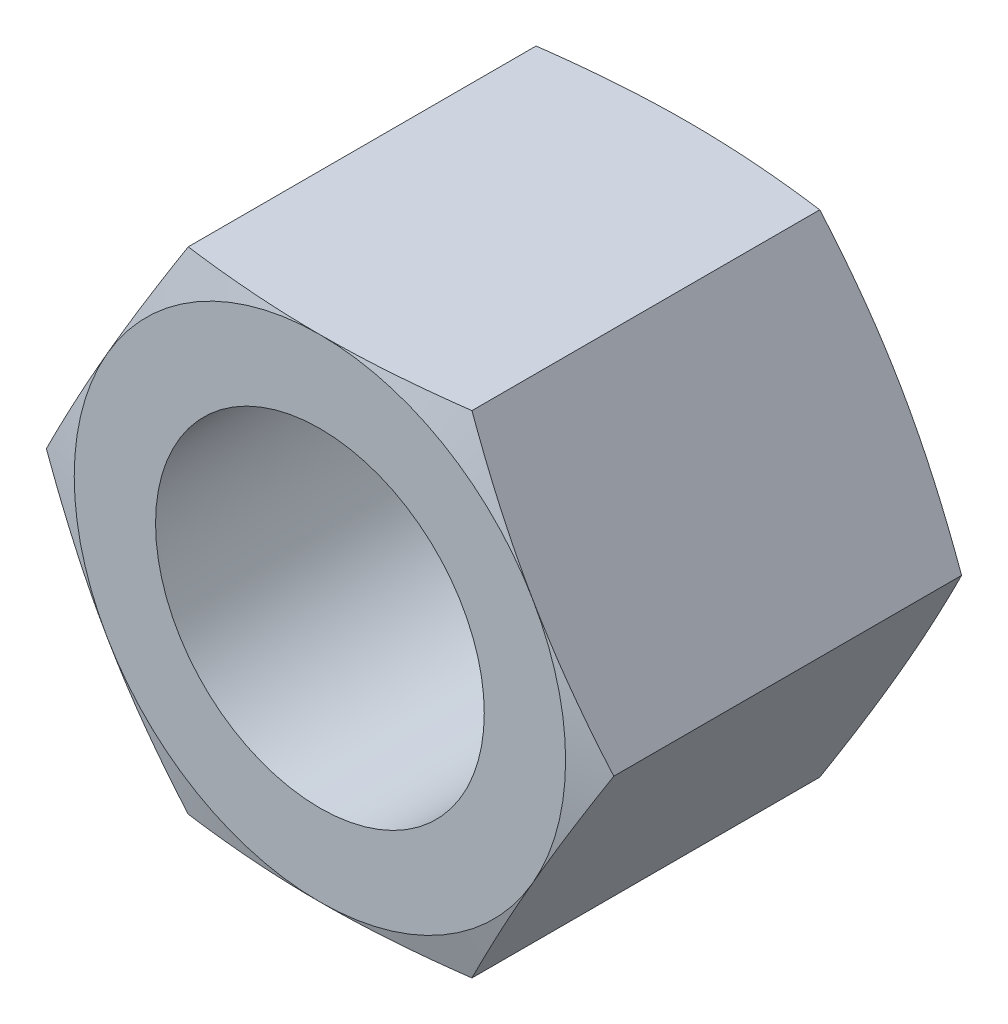
from build123d import *

# Parameters (mm, degrees)
SKETCH_1_R          = 2.5
EXTRUDE_550_DEPTH   = 5.6
SKETCH_2_OUTSIDE_W  = 296.81
SKETCH_2_OUTSIDE_H  = 295.654
SKETCH_2_OUTSIDE_R  = 3.736899617
CUT_EXTRUDE_1_DEPTH = 38
CUT_EXTRUDE_1_TAPER = 75
SKETCH_3_OUTSIDE_W  = 296.81
SKETCH_3_OUTSIDE_H  = 295.654
SKETCH_3_OUTSIDE_R  = 3.736899617
CUT_EXTRUDE_2_DEPTH = 38
CUT_EXTRUDE_2_TAPER = 75


with BuildPart() as part:
    # 草图1 → Extrude 550 (new body)
    with BuildSketch(Plane.XY):
        Polygon((2.1575, 3.736899617), (-2.1575, 3.736899617), (-4.315, 0), (-2.1575, -3.736899617), (2.1575, -3.736899617), (4.315, 0), align=None)
        Circle(SKETCH_1_R, mode=Mode.SUBTRACT)
    extrude(amount=EXTRUDE_550_DEPTH)

    # 草图2 outside → 切除-拉伸1 (cut)
    with BuildSketch(Plane(origin=(0, 0, 0), x_dir=(-1, 0, 0), z_dir=(0, 0, -1))):
        Rectangle(SKETCH_2_OUTSIDE_W, SKETCH_2_OUTSIDE_H)
        Circle(SKETCH_2_OUTSIDE_R, mode=Mode.SUBTRACT)
    extrude(amount=-CUT_EXTRUDE_1_DEPTH, taper=CUT_EXTRUDE_1_TAPER, mode=Mode.SUBTRACT)

    # 草图3 outside → 切除-拉伸2 (cut)
    with BuildSketch(Plane.XY.offset(5.6)):
        Rectangle(SKETCH_3_OUTSIDE_W, SKETCH_3_OUTSIDE_H)
        Circle(SKETCH_3_OUTSIDE_R, mode=Mode.SUBTRACT)
    extrude(amount=-CUT_EXTRUDE_2_DEPTH, taper=CUT_EXTRUDE_2_TAPER, mode=Mode.SUBTRACT)


solid = part.part
